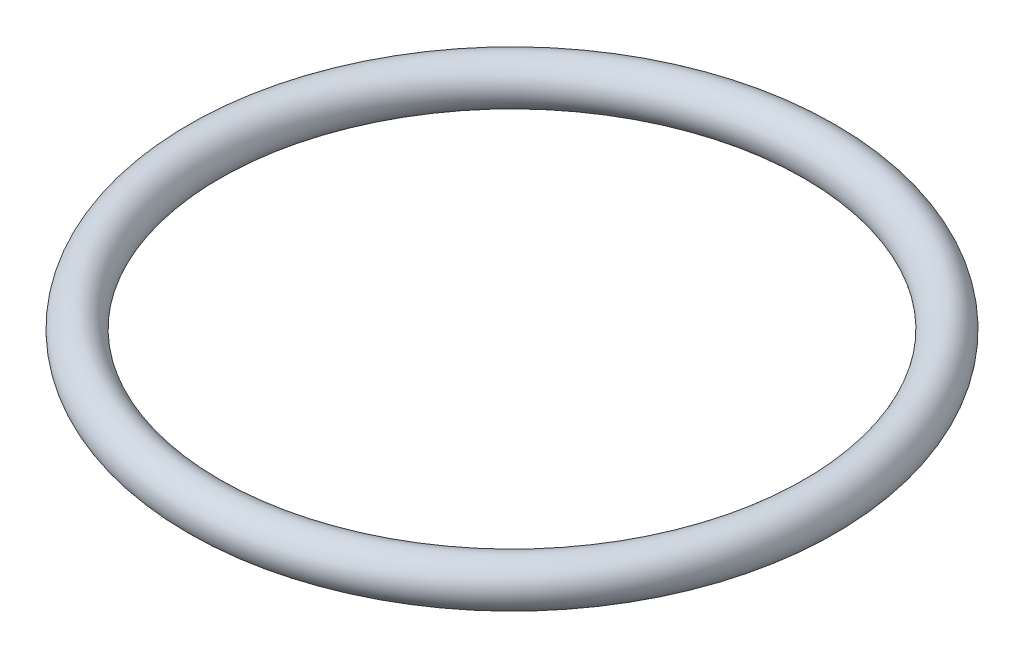
from build123d import *

# Parameters (mm, degrees)
SKETCH2_R = 3.175


with BuildPart() as part:
    # Sweep1: sweep along a path in Sketch1
    with BuildLine(Plane(origin=(0, 0, 0), x_dir=(1, 0, 0), z_dir=(0, 1, 0))) as sweep1_path:
        CenterArc((0, 0), 44.45, 0, 360)
    # Sketch2 → Sweep1 (sweep)
    with BuildSketch(Plane(origin=(0, 0, 0), x_dir=(0, 0, -1), z_dir=(1, 0, 0))):
        with Locations((44.45, 0)):
            Circle(SKETCH2_R)
    sweep(path=sweep1_path.line)


solid = part.part
